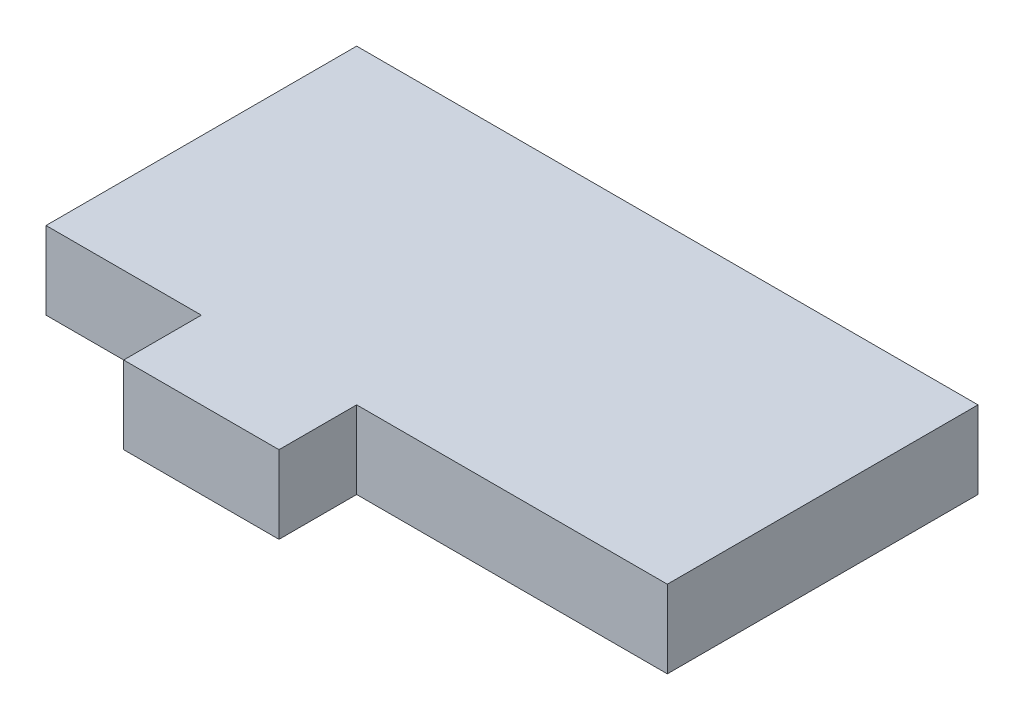
from build123d import *

# Parameters (mm, degrees)
SKETCH1_W           = 12.7
SKETCH1_H           = 6.35
SKETCH1_W_2         = 50.8
SKETCH1_H_2         = 25.4
BOSS_EXTRUDE1_DEPTH = 6.35


with BuildPart() as part:
    # Sketch1 → Boss-Extrude1 (new body)
    with BuildSketch(Plane(origin=(0, 0, 0), x_dir=(1, 0, 0), z_dir=(0, 1, 0))):
        with Locations((19.05, -3.175)):
            Rectangle(SKETCH1_W, SKETCH1_H)
        with Locations((25.4, 12.7)):
            Rectangle(SKETCH1_W_2, SKETCH1_H_2)
    extrude(amount=BOSS_EXTRUDE1_DEPTH)


solid = part.part
